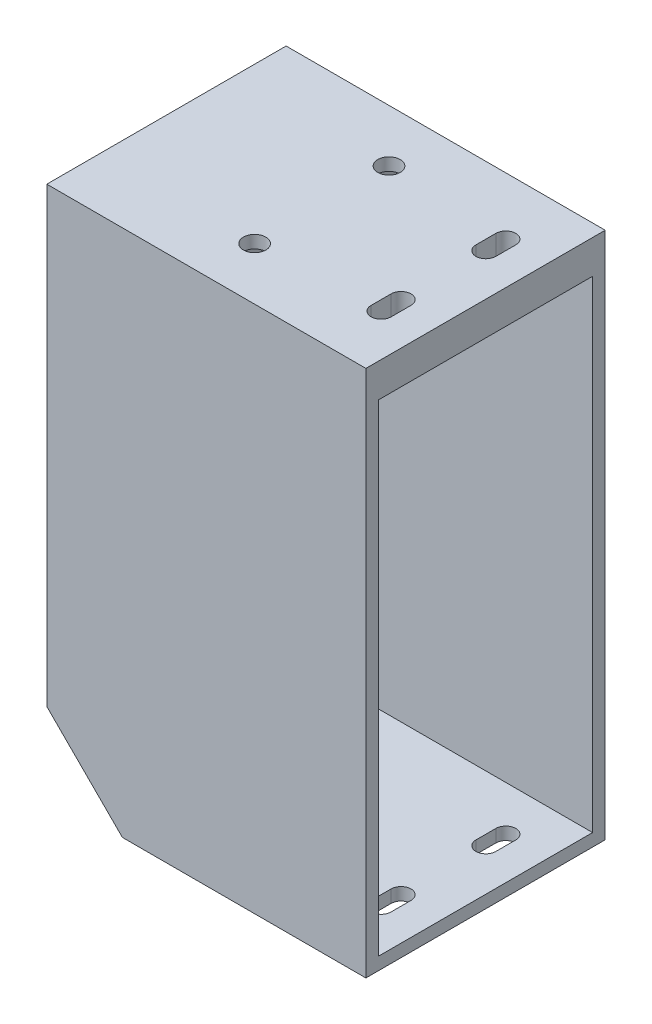
from build123d import *

# Parameters (mm, degrees)
SKETCH2_W           = 57
SKETCH2_H           = 120.75
SKETCH2_W_2         = 51
SKETCH2_H_2         = 114.75
BOSS_EXTRUDE1_DEPTH = 75
SKETCH3_W           = 57
SKETCH3_H           = 120.75
BOSS_EXTRUDE2_DEPTH = 3
SKETCH4_W           = 78
SKETCH4_H           = 57
BOSS_EXTRUDE3_DEPTH = 5
SKETCH6_R           = 2.675
CUT_EXTRUDE2_DEPTH  = 10
CUT_EXTRUDE3_DEPTH  = 58
BOSS_EXTRUDE4_REACH = 59
CUT_EXTRUDE7_DEPTH  = 126.75
SKETCH18_R          = 1.75
SKETCH18_W          = 28.5
SKETCH18_H          = 55
CUT_EXTRUDE8_DEPTH  = 10
BOSS_EXTRUDE6_DEPTH = 5
CUT_EXTRUDE9_DEPTH  = 5
CHAMFER1_SIZE       = 2


with BuildPart() as part:
    # Sketch2 → Boss-Extrude1 (new body)
    with BuildSketch(Plane(origin=(0, 0, 0), x_dir=(0, 0, -1), z_dir=(1, 0, 0))):
        with Locations((2.896243414, -39.494242434)):
            Rectangle(SKETCH2_W, SKETCH2_H)
        with Locations((2.896243414, -39.494242434)):
            Rectangle(SKETCH2_W_2, SKETCH2_H_2, mode=Mode.SUBTRACT)
    extrude(amount=BOSS_EXTRUDE1_DEPTH)

    # Sketch3 → Boss-Extrude2 (add)
    with BuildSketch(Plane.ZY):
        with Locations((-2.896243414, -39.494242434)):
            Rectangle(SKETCH3_W, SKETCH3_H)
    extrude(amount=BOSS_EXTRUDE2_DEPTH)

    # Sketch4 → Boss-Extrude3 (add)
    with BuildSketch(Plane(origin=(0, 20.880757566, 0), x_dir=(1, 0, 0), z_dir=(0, 1, 0))):
        with Locations((36, 2.896243414)):
            Rectangle(SKETCH4_W, SKETCH4_H)
    extrude(amount=BOSS_EXTRUDE3_DEPTH)

    # Sketch6 → Cut-Extrude2 (cut)
    with BuildSketch(Plane(origin=(0, 25.880757566, 0), x_dir=(1, 0, 0), z_dir=(0, 1, 0))):
        with Locations((36, 18.896243414)):
            Circle(SKETCH6_R)
        with Locations((36, -13.103756586)):
            Circle(SKETCH6_R)
    extrude(amount=-CUT_EXTRUDE2_DEPTH, mode=Mode.SUBTRACT)

    # Sketch8 → Cut-Extrude3 (cut, through all)
    with BuildSketch(Plane(origin=(0, 0, -31.396243414), x_dir=(-1, 0, 0), z_dir=(0, 0, -1))):
        Polygon((3, -99.869242434), (3, -79.869242434), (-17, -99.869242434), align=None)
    extrude(amount=-CUT_EXTRUDE3_DEPTH, mode=Mode.SUBTRACT)

    # Sketch9 → Boss-Extrude4 (add, up to next)
    with BuildSketch(Plane.XY.offset(25.603756586), mode=Mode.PRIVATE) as boss_extrude4_sk1:
        Polygon((-3, -79.869242434), (17, -99.869242434), (21.242640687, -99.869242434), (-3, -75.626601747), align=None)
    boss_extrude4_tool1 = extrude(boss_extrude4_sk1.sketch, amount=-BOSS_EXTRUDE4_REACH, mode=Mode.PRIVATE) - part.part
    add(boss_extrude4_tool1.solids().sort_by_distance((8.094564, -88.774678, 25.603757))[0])

    # Sketch15 → Cut-Extrude7 (cut, through all)
    with BuildSketch(Plane.XZ.offset(99.869242434)):
        with BuildLine():
            Line((62.625, 7.226342188), (62.625, 11.976342188))
            ThreePointArc((62.625, 11.976342188), (65, 14.351342188), (67.375, 11.976342188))
            Line((67.375, 11.976342188), (67.375, 7.226342188))
            ThreePointArc((67.375, 7.226342188), (65, 4.851342188), (62.625, 7.226342188))
        make_face()
        with BuildLine():
            Line((62.625, -17.72757696), (62.625, -12.97757696))
            ThreePointArc((62.625, -12.97757696), (65, -10.60257696), (67.375, -12.97757696))
            Line((67.375, -12.97757696), (67.375, -17.72757696))
            ThreePointArc((67.375, -17.72757696), (65, -20.10257696), (62.625, -17.72757696))
        make_face()
    extrude(amount=-CUT_EXTRUDE7_DEPTH, mode=Mode.SUBTRACT)

    # Sketch18 → Cut-Extrude8 (cut)
    with BuildSketch(Plane.ZY.offset(3)):
        with Locations((-22.896243414, -14.119242434)):
            Circle(SKETCH18_R)
        with Locations((17.103756586, -14.119242434)):
            Circle(SKETCH18_R)
        with Locations((-2.896243414, -14.119242434)):
            Rectangle(SKETCH18_W, SKETCH18_H)
    extrude(amount=-CUT_EXTRUDE8_DEPTH, mode=Mode.SUBTRACT)

    # Sketch21 → Boss-Extrude6 (add)
    with BuildSketch(Plane(origin=(0, 0, 0), x_dir=(0, 0, -1), z_dir=(1, 0, 0))):
        with BuildLine():
            Line((22.896243414, -19.869242434), (28.646243414, -19.869242434))
            Line((28.646243414, -19.869242434), (28.646243414, -8.369242434))
            Line((28.646243414, -8.369242434), (22.896243414, -8.369242434))
            ThreePointArc((22.896243414, -8.369242434), (17.146243414, -14.119242434), (22.896243414, -19.869242434))
        make_face()
        Polygon((19.518744339, -14.119242434), (21.207493877, -11.194242434), (24.584992952, -11.194242434), (26.273742489, -14.119242434), (24.584992952, -17.044242434), (21.207493877, -17.044242434), align=None, mode=Mode.SUBTRACT)
        with BuildLine():
            Line((-17.103756586, -19.869242434), (-22.853756586, -19.869242434))
            Line((-22.853756586, -19.869242434), (-22.853756586, -8.369242434))
            Line((-22.853756586, -8.369242434), (-17.103756586, -8.369242434))
            ThreePointArc((-17.103756586, -8.369242434), (-11.353756586, -14.119242434), (-17.103756586, -19.869242434))
        make_face()
        Polygon((-15.415007048, -11.194242434), (-18.792506123, -11.194242434), (-20.481255661, -14.119242434), (-18.792506123, -17.044242434), (-15.415007048, -17.044242434), (-13.726257511, -14.119242434), align=None, mode=Mode.SUBTRACT)
    extrude(amount=BOSS_EXTRUDE6_DEPTH)

    # Sketch22 → Cut-Extrude9 (cut)
    with BuildSketch(Plane.XZ.offset(-17.880757566)):
        Polygon((40.820874748, -18.896243414), (38.410437374, -14.721243414), (33.589562626, -14.721243414), (31.179125252, -18.896243414), (33.589562626, -23.071243414), (38.410437374, -23.071243414), align=None)
        Polygon((38.410437374, 17.278756586), (40.820874748, 13.103756586), (38.410437374, 8.928756586), (33.589562626, 8.928756586), (31.179125252, 13.103756586), (33.589562626, 17.278756586), align=None)
    extrude(amount=-CUT_EXTRUDE9_DEPTH, mode=Mode.SUBTRACT)

    # Chamfer1
    chamfer1_edges = [part.edges().sort_by_distance(p)[0] for p in [
        (-3, -26.994242434, -31.396243414),
        (-3, 25.880757566, -2.896243414),
        (-3, -26.994242434, 25.603756586),
    ]]
    chamfer(chamfer1_edges, length=CHAMFER1_SIZE)


solid = part.part
